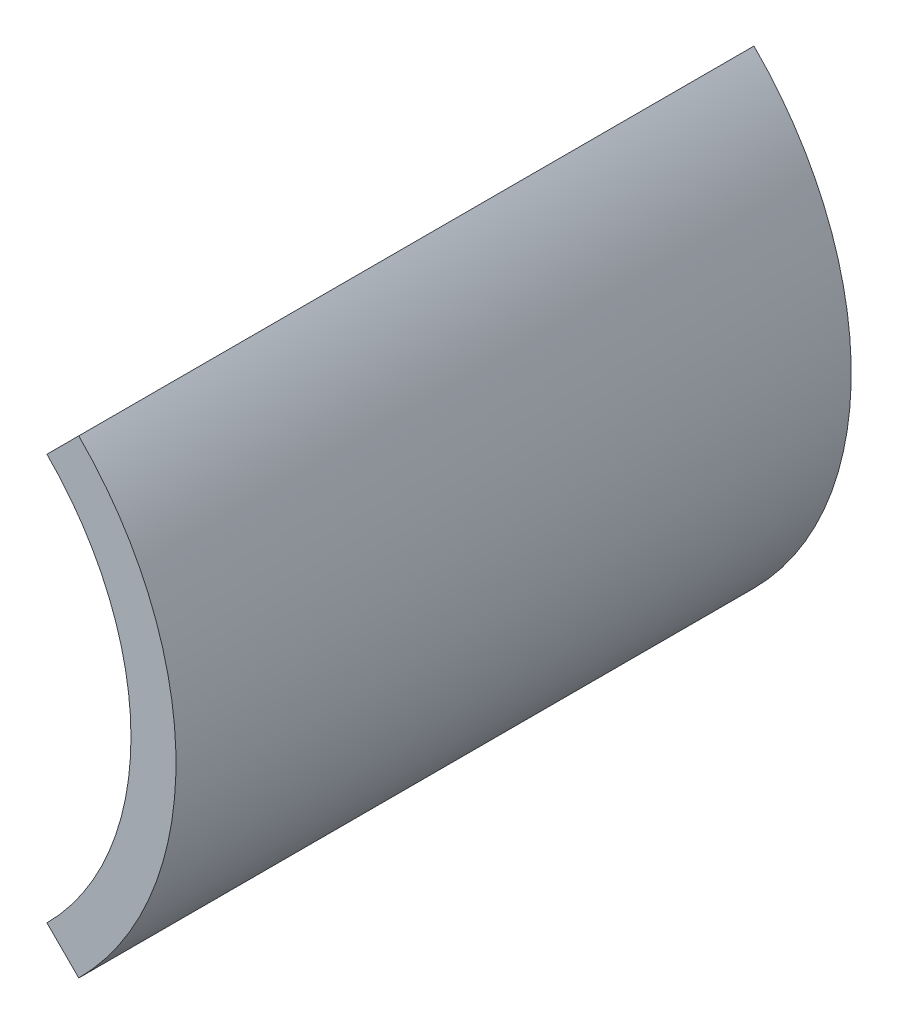
from build123d import *

# Parameters (mm, degrees)
BOSS_EXTRUDE1_DEPTH = 15


with BuildPart() as part:
    # Sketch1 → Boss-Extrude1 (new body, symmetric)
    with BuildSketch(Plane.XY):
        with BuildLine():
            Line((9.01561146, 9.01561146), (10.429825023, 10.429825023))
            ThreePointArc((10.429825023, 10.429825023), (14.75, 0), (10.429825023, -10.429825023))
            Line((10.429825023, -10.429825023), (9.01561146, -9.01561146))
            ThreePointArc((9.01561146, -9.01561146), (12.75, 0), (9.01561146, 9.01561146))
        make_face()
    extrude(amount=BOSS_EXTRUDE1_DEPTH, both=True)


solid = part.part
